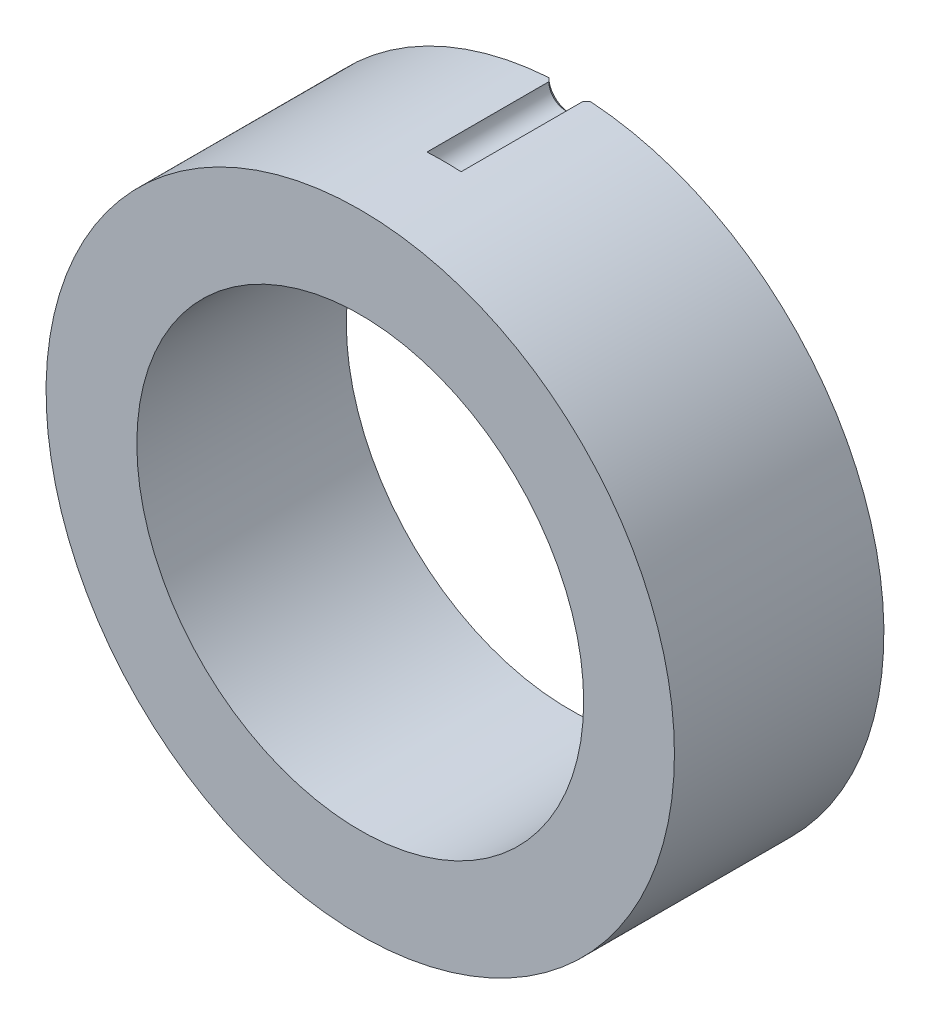
from build123d import *

# Parameters (mm, degrees)
SKETCH_1_R          = 45
SKETCH_1_R_2        = 32
EXTRUDE_1_DEPTH     = 30
SKETCH_2_R          = 2.4455
CUT_EXTRUDE_1_DEPTH = 18
CHAMFER_1_SIZE      = 0.5545


with BuildPart() as part:
    # Эскиз1 → Бобышка-Вытянуть1 (new body)
    with BuildSketch(Plane.XY):
        Circle(SKETCH_1_R)
        Circle(SKETCH_1_R_2, mode=Mode.SUBTRACT)
    extrude(amount=EXTRUDE_1_DEPTH)

    # Эскиз2 → Вырез-Вытянуть1 (cut)
    with BuildSketch(Plane(origin=(0, 0, 0), x_dir=(-1, 0, 0), z_dir=(0, 0, -1))):
        with Locations((0, 45)):
            Circle(SKETCH_2_R)
    extrude(amount=-CUT_EXTRUDE_1_DEPTH, mode=Mode.SUBTRACT)

    # Фаска1
    chamfer_1_edges = [part.edges().sort_by_distance(p)[0] for p in [
        (0, 42.5545, 0),
    ]]
    chamfer(chamfer_1_edges, length=CHAMFER_1_SIZE)


solid = part.part
